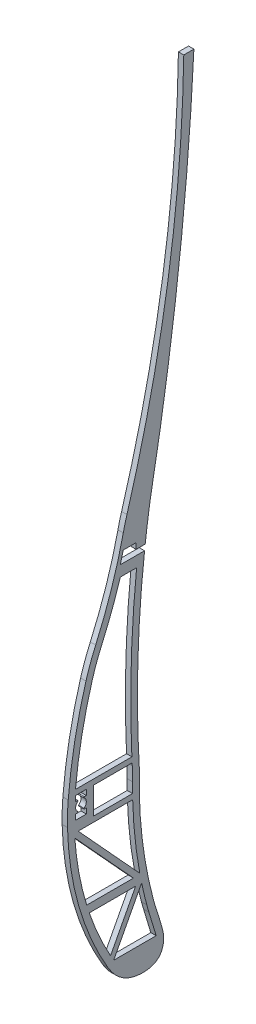
from build123d import *

# Parameters (mm, degrees)
BOSS_EXTRUDE3_DEPTH = 2


with BuildPart() as part:
    # rib1 → Boss-Extrude3 (new body)
    with BuildSketch(Plane(origin=(0, 0, 0), x_dir=(0, 0, -1), z_dir=(1, 0, 0))):
        with BuildLine():
            Line((884.190402355, 599.903880086), (887.974497078, 599.903880086))
            ThreePointArc((887.974497078, 599.903880086), (882.263270905, 531.637412846), (871.936760509, 463.915246337))
            ThreePointArc((871.936760509, 463.915246337), (871.707754952, 462.63585681), (871.499564589, 461.352915705))
            ThreePointArc((871.499564589, 461.352915705), (870.595346832, 455.153887164), (869.789272098, 448.9413347))
            Line((869.789272098, 448.9413347), (866.401149721, 448.919807544))
            Line((866.401149721, 448.919807544), (866.401149721, 451.102816327))
            Line((866.401149721, 451.102816327), (861.608127253, 451.102816327))
            Line((861.608127253, 451.102816327), (860.510379387, 446.915494441))
            Line((860.510379387, 446.915494441), (865.375229135, 446.915494441))
            Line((865.375229135, 446.915494441), (869.54798498, 446.915494441))
            ThreePointArc((869.54798498, 446.915494441), (867.037221046, 411.983470834), (867.621553236, 376.966207023))
            ThreePointArc((867.621553236, 376.966207023), (868.612160303, 354.616141956), (872.80220547, 332.640013262))
            ThreePointArc((872.80220547, 332.640013262), (873.47434667, 330.265780469), (874.219390873, 327.913406289))
            add(Edge.make_bspline(
                [(855.857880167, 318.999188197), (859.364761712, 313.05960504), (867.053375546, 309.847722104), (875.890724025, 311.576721792), (877.047226337, 317.875748314), (875.730897291, 323.262688208), (874.992082107, 325.59839708), (874.219390873, 327.913406289)],
                knots=[0, 0, 0, 0, 0.275025565, 0.518183074, 0.708505616, 0.751926805, 0.952394957, 0.952394957, 0.952394957, 0.952394957], degree=3))
            ThreePointArc((855.857880167, 318.999188197), (844.952134323, 344.441967913), (840.778778225, 371.807154391))
            ThreePointArc((840.778778225, 371.807154391), (840.791401867, 376.192855714), (841.044346896, 380.571274865))
            ThreePointArc((841.044346896, 380.571274865), (843.467649147, 398.313507068), (847.671804222, 415.719950629))
            ThreePointArc((847.671804222, 415.719950629), (849.322478828, 420.694724685), (851.295375271, 425.550729544))
            ThreePointArc((851.295375271, 425.550729544), (857.21755567, 440.844099615), (861.608127253, 456.645437216))
            ThreePointArc((861.608127253, 456.645437216), (862.250861952, 459.285693699), (862.982894629, 461.902598426))
            ThreePointArc((862.982894629, 461.902598426), (878.329662766, 530.174351012), (884.190402355, 599.903880086))
        make_face()
        with BuildLine():
            Line((856.934499706, 370.641580619), (865.074501074, 370.641580619))
            ThreePointArc((865.074501074, 370.641580619), (865.061715716, 372.55284998), (865.072069166, 374.464134061))
            ThreePointArc((865.072069166, 374.464134061), (865.059488848, 377.071259141), (864.961961737, 379.676589813))
            ThreePointArc((864.961961737, 379.676589813), (864.936315213, 380.159069851), (864.911253489, 380.641580619))
            Line((864.911253489, 380.641580619), (855.857880167, 380.641580619))
            Line((855.857880167, 380.641580619), (850.434499706, 380.641580619))
            Line((850.434499706, 380.641580619), (850.434499706, 379.641580619))
            Line((850.434499706, 379.641580619), (850.434499706, 376.641580619))
            Line((850.434499706, 376.641580619), (850.434499706, 373.641580619))
            Line((850.434499706, 373.641580619), (850.434499706, 370.641580619))
            Line((850.434499706, 370.641580619), (856.934499706, 370.641580619))
        make_face(mode=Mode.SUBTRACT)
        with BuildLine():
            Line((843.806259463, 374.641580619), (843.806259463, 372.641580619))
            Line((843.806259463, 372.641580619), (847.806259463, 372.641580619))
            Line((847.806259463, 372.641580619), (847.806259463, 374.641580619))
            Line((847.806259463, 374.641580619), (847.071170527, 374.641580619))
            ThreePointArc((847.071170527, 374.641580619), (846.880478009, 374.78127835), (846.956178612, 375.005216983))
            ThreePointArc((846.956178612, 375.005216983), (847.806259463, 376.641580619), (846.956178612, 378.277944256))
            ThreePointArc((846.956178612, 378.277944256), (846.880478009, 378.501882888), (847.071170527, 378.641580619))
            Line((847.071170527, 378.641580619), (847.806259463, 378.641580619))
            Line((847.806259463, 378.641580619), (847.806259463, 380.641580619))
            Line((847.806259463, 380.641580619), (843.806259463, 380.641580619))
            Line((843.806259463, 380.641580619), (843.806259463, 378.641580619))
            Line((843.806259463, 378.641580619), (844.541348398, 378.641580619))
            ThreePointArc((844.541348398, 378.641580619), (844.732040916, 378.501882888), (844.656340313, 378.277944256))
            ThreePointArc((844.656340313, 378.277944256), (843.806259463, 376.641580619), (844.656340313, 375.005216983))
            ThreePointArc((844.656340313, 375.005216983), (844.732040916, 374.78127835), (844.541348398, 374.641580619))
            Line((844.541348398, 374.641580619), (843.806259463, 374.641580619))
        make_face(mode=Mode.SUBTRACT)
        with BuildLine():
            Line((855.857880167, 382.641580619), (843.745202867, 382.641580619))
            ThreePointArc((843.745202867, 382.641580619), (846.140446491, 398.975976663), (850.069113586, 415.010790694))
            ThreePointArc((850.069113586, 415.010790694), (851.66820461, 419.830103061), (853.57944804, 424.534357768))
            ThreePointArc((853.57944804, 424.534357768), (857.311934253, 433.624241307), (860.510379387, 442.915494441))
            Line((860.510379387, 442.915494441), (866.588621263, 442.915494441))
            ThreePointArc((866.588621263, 442.915494441), (864.559820273, 412.812147569), (864.813623932, 382.641580619))
            Line((864.813623932, 382.641580619), (855.857880167, 382.641580619))
        make_face(mode=Mode.SUBTRACT)
        with BuildLine():
            Line((856.934499706, 368.641580619), (844.761871726, 368.641580619))
            Line((844.761871726, 368.641580619), (867.775159476, 343.508235636))
            ThreePointArc((867.775159476, 343.508235636), (865.940167273, 356.021544161), (865.112661127, 368.641580619))
            Line((865.112661127, 368.641580619), (856.934499706, 368.641580619))
        make_face(mode=Mode.SUBTRACT)
        with BuildLine():
            Line((866.220437017, 340.129064892), (848.91695937, 340.129064892))
            ThreePointArc((848.91695937, 340.129064892), (852.472162499, 331.037884456), (856.841512929, 322.308748884))
            Line((856.841512929, 322.308748884), (866.220437017, 340.129064892))
        make_face(mode=Mode.SUBTRACT)
        with BuildLine():
            Line((858.312156349, 320.808777779), (858.026910258, 320.266799251))
            Line((858.026910258, 320.266799251), (873.886224652, 320.266799251))
            Line((873.886224652, 320.266799251), (871.179687831, 329.216724417))
            ThreePointArc((871.179687831, 329.216724417), (870.770932499, 330.602992637), (870.386524281, 331.996208637))
            ThreePointArc((870.386524281, 331.996208637), (869.368691994, 336.027959273), (868.457393024, 340.085117137))
            Line((868.457393024, 340.085117137), (858.312156349, 320.808777779))
        make_face(mode=Mode.SUBTRACT)
        with BuildLine():
            Line((848.420317738, 343.129064892), (847.948092292, 343.129064892))
            ThreePointArc((847.948092292, 343.129064892), (845.043868959, 354.964134396), (843.504907333, 367.052764611))
            Line((843.504907333, 367.052764611), (865.410586264, 343.129064892))
            Line((865.410586264, 343.129064892), (848.420317738, 343.129064892))
        make_face(mode=Mode.SUBTRACT)
    extrude(amount=BOSS_EXTRUDE3_DEPTH)


solid = part.part
